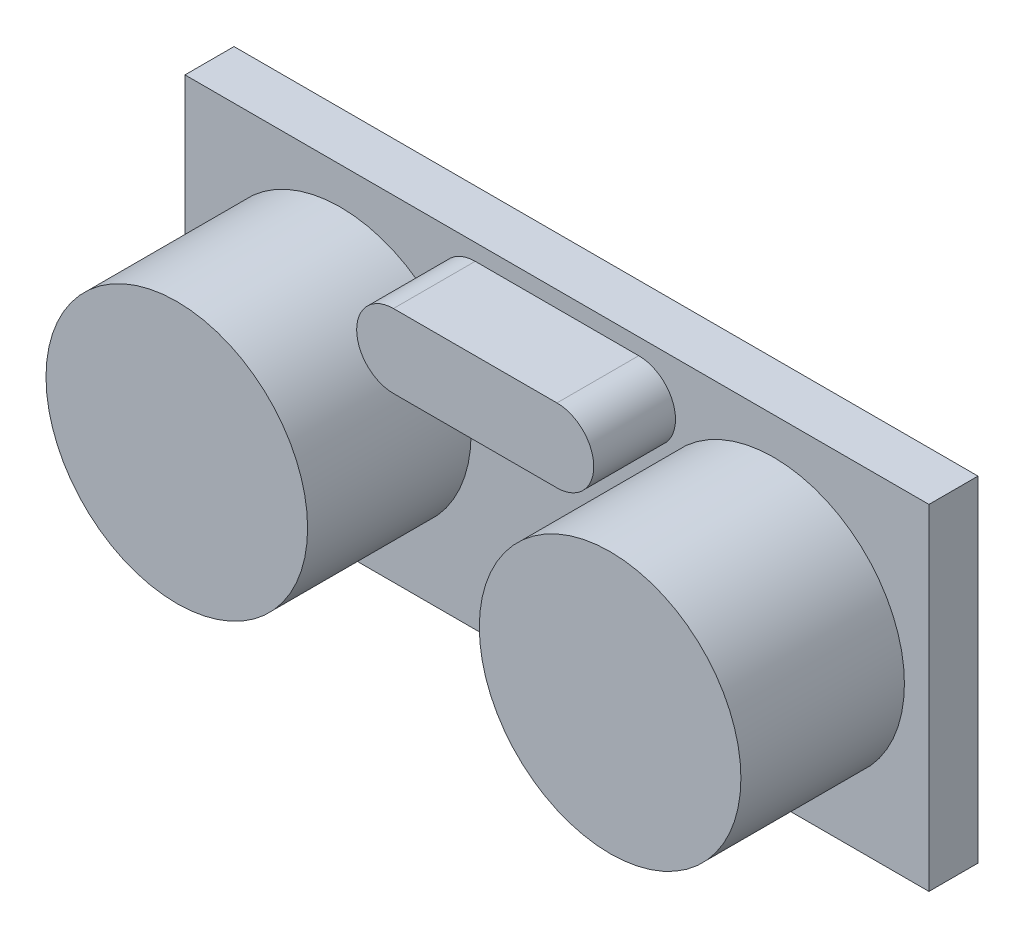
from build123d import *

# Parameters (mm, degrees)
SKETCH1_W           = 45.5
SKETCH1_H           = 20.5
SKETCH1_R           = 8
BOSS_EXTRUDE1_DEPTH = 3
SKETCH2_R           = 8
BOSS_EXTRUDE3_DEPTH = 10
BOSS_EXTRUDE4_DEPTH = 5
SKETCH3_W           = 2.5
SKETCH3_H           = 2.5
SKETCH3_R           = 0.5
BOSS_EXTRUDE5_DEPTH = 3
SKETCH3_2_R         = 0.5
BOSS_EXTRUDE6_DEPTH = 10


with BuildPart() as part:
    # Sketch1 → Boss-Extrude1 (new body)
    with BuildSketch(Plane.XY):
        Rectangle(SKETCH1_W, SKETCH1_H)
        with Locations((-13.25, 0)):
            Circle(SKETCH1_R, mode=Mode.SUBTRACT)
        with Locations((13.25, 0)):
            Circle(SKETCH1_R, mode=Mode.SUBTRACT)
        with BuildLine():
            ThreePointArc((5, 4.75), (7.25, 7), (5, 9.25))
            Line((5, 9.25), (-5, 9.25))
            ThreePointArc((-5, 9.25), (-7.25, 7), (-5, 4.75))
            Line((-5, 4.75), (5, 4.75))
        make_face(mode=Mode.SUBTRACT)
        with Locations((-13.25, 0)):
            Circle(SKETCH1_R)
        with BuildLine():
            Line((-5, 4.75), (5, 4.75))
            ThreePointArc((5, 4.75), (7.25, 7), (5, 9.25))
            Line((5, 9.25), (-5, 9.25))
            ThreePointArc((-5, 9.25), (-7.25, 7), (-5, 4.75))
        make_face()
        with Locations((13.25, 0)):
            Circle(SKETCH1_R)
    extrude(amount=BOSS_EXTRUDE1_DEPTH)

    # Sketch2 → Boss-Extrude3 (add)
    with BuildSketch(Plane.XY.offset(3)):
        with Locations((-13.25, 0)):
            Circle(SKETCH2_R)
        with Locations((13.25, 0)):
            Circle(SKETCH2_R)
    extrude(amount=BOSS_EXTRUDE3_DEPTH)

    # Sketch2_7 → Boss-Extrude4 (add)
    with BuildSketch(Plane.XY.offset(3)):
        with BuildLine():
            Line((-5, 4.75), (5, 4.75))
            ThreePointArc((5, 4.75), (7.25, 7), (5, 9.25))
            Line((5, 9.25), (-5, 9.25))
            ThreePointArc((-5, 9.25), (-7.25, 7), (-5, 4.75))
        make_face()
    extrude(amount=BOSS_EXTRUDE4_DEPTH)

    # Sketch3 → Boss-Extrude5 (add)
    with BuildSketch(Plane(origin=(0, 0, 0), x_dir=(-1, 0, 0), z_dir=(0, 0, -1))):
        with Locations((-1.27, -8.75)):
            Rectangle(SKETCH3_W, SKETCH3_H)
        with Locations((-1.27, -8.75)):
            Circle(SKETCH3_R, mode=Mode.SUBTRACT)
        with Locations((-3.81, -8.75)):
            Rectangle(SKETCH3_W, SKETCH3_H)
        with Locations((-3.81, -8.75)):
            Circle(SKETCH3_R, mode=Mode.SUBTRACT)
        with Locations((1.27, -8.75)):
            Rectangle(SKETCH3_W, SKETCH3_H)
        with Locations((1.27, -8.75)):
            Circle(SKETCH3_R, mode=Mode.SUBTRACT)
        with Locations((3.81, -8.75)):
            Rectangle(SKETCH3_W, SKETCH3_H)
        with Locations((3.81, -8.75)):
            Circle(SKETCH3_R, mode=Mode.SUBTRACT)
    extrude(amount=BOSS_EXTRUDE5_DEPTH)

    # Sketch3_2 → Boss-Extrude6 (add)
    with BuildSketch(Plane(origin=(0, 0, 0), x_dir=(-1, 0, 0), z_dir=(0, 0, -1))):
        with Locations((-3.81, -8.75)):
            Circle(SKETCH3_2_R)
        with Locations((-1.27, -8.75)):
            Circle(SKETCH3_2_R)
        with Locations((1.27, -8.75)):
            Circle(SKETCH3_2_R)
        with Locations((3.81, -8.75)):
            Circle(SKETCH3_2_R)
    extrude(amount=BOSS_EXTRUDE6_DEPTH)


solid = part.part
